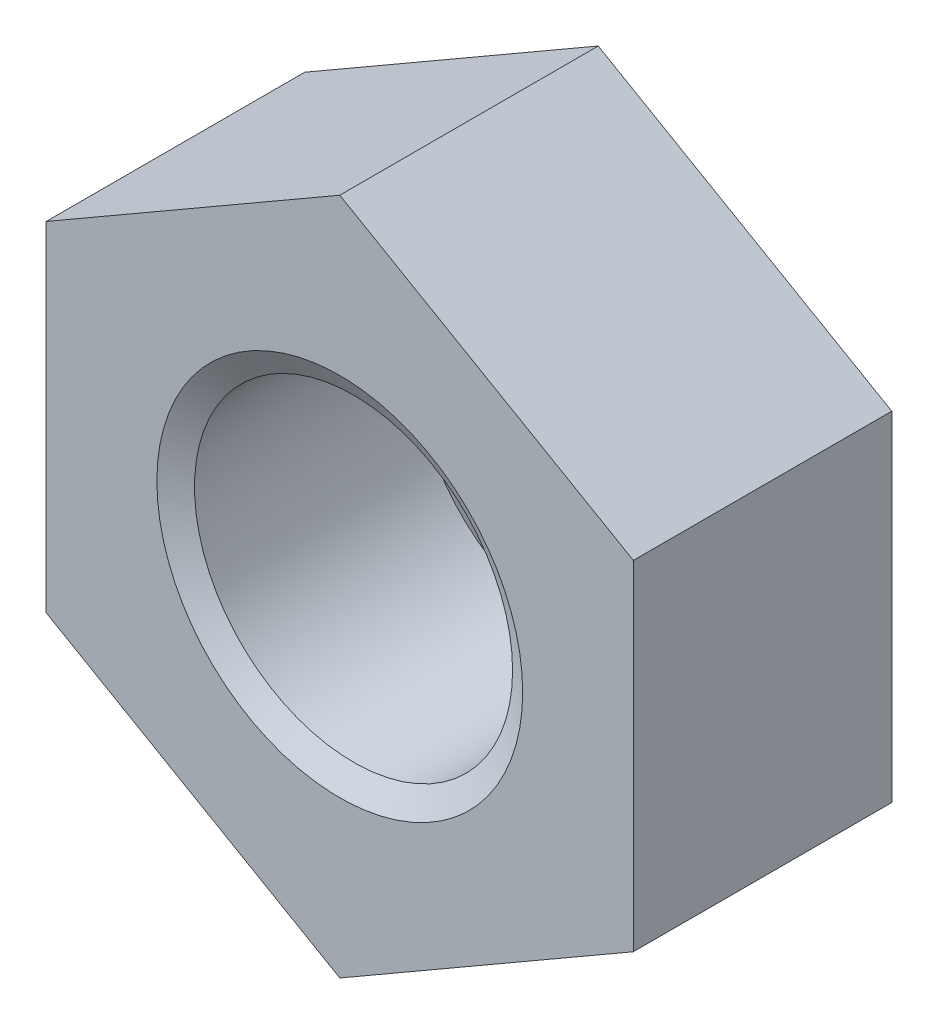
from build123d import *

# Parameters (mm, degrees)
SKETCH_1_R             = 0.8
EXTRUDE_1_DEPTH        = 1.3
CHAMFER_1_SIZE         = 0.12
CHAMFER_1_SIZE2        = 0.069282032
CHAMFER_1_PART_2_SIZE  = 0.12
CHAMFER_1_PART_2_SIZE2 = 0.069282032


with BuildPart() as part:
    # Эскиз1 → Бобышка-Вытянуть1 (new body)
    with BuildSketch(Plane.XY):
        Polygon((0, 1.705), (-1.476573313, 0.8525), (-1.476573313, -0.8525), (0, -1.705), (1.476573313, -0.8525), (1.476573313, 0.8525), align=None)
        Circle(SKETCH_1_R, mode=Mode.SUBTRACT)
    extrude(amount=EXTRUDE_1_DEPTH)

    # Фаска1
    chamfer_1_edges = [part.edges().sort_by_distance(p)[0] for p in [
        (-0.8, 0, 0),
    ]]
    chamfer_1_side = [part.faces().sort_by_distance(p)[0] for p in [
        (-0.8, 0, 0.65),
    ]]
    chamfer(chamfer_1_edges, length=CHAMFER_1_SIZE, length2=CHAMFER_1_SIZE2, reference=chamfer_1_side[0])

    # Фаска1 part 2
    chamfer_1_part_2_edges = [part.edges().sort_by_distance(p)[0] for p in [
        (-0.8, 0, 1.3),
    ]]
    chamfer_1_part_2_side = [part.faces().sort_by_distance(p)[0] for p in [
        (-0.715731627, 1.239683542, 1.3),
    ]]
    chamfer(chamfer_1_part_2_edges, length=CHAMFER_1_PART_2_SIZE, length2=CHAMFER_1_PART_2_SIZE2, reference=chamfer_1_part_2_side[0])


solid = part.part
